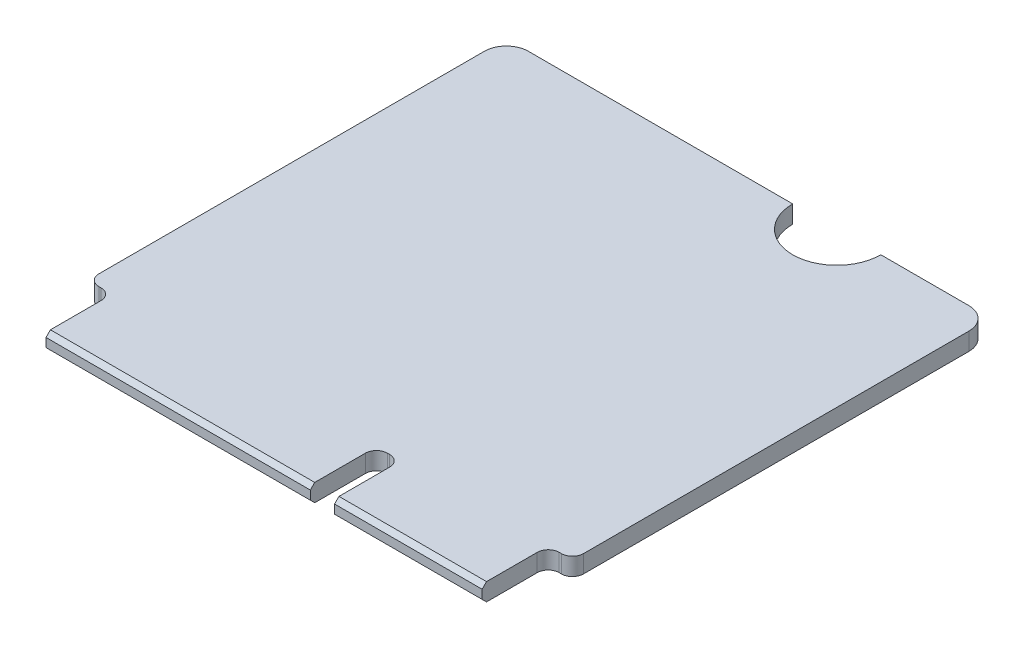
from build123d import *

# Parameters (mm, degrees)
BOSS_EXTRUDE1_DEPTH = 0.8
FILLET1_R           = 1
FILLET2_R           = 0.5
CHAMFER1_SIZE       = 0.2


with BuildPart() as part:
    # Sketch1 → Boss-Extrude1 (new body)
    with BuildSketch(Plane(origin=(0, 0, 0), x_dir=(1, 0, 0), z_dir=(0, 1, 0))):
        with BuildLine():
            Line((14.2, -22), (20.9, -22))
            Line((20.9, -22), (20.9, -19))
            Line((20.9, -19), (22, -19))
            Line((22, -19), (22, 0))
            Line((22, 0), (17, 0))
            ThreePointArc((17, 0), (15, -2), (13, 0))
            Line((13, 0), (0, 0))
            Line((0, 0), (0, -19))
            Line((0, -19), (1.1, -19))
            Line((1.1, -19), (1.1, -22))
            Line((1.1, -22), (13.1, -22))
            Line((13.1, -22), (13.1, -19))
            Line((13.1, -19), (14.2, -19))
            Line((14.2, -19), (14.2, -22))
        make_face()
    extrude(amount=BOSS_EXTRUDE1_DEPTH)

    # Fillet1
    fillet1_edges = [part.edges().sort_by_distance(p)[0] for p in [
        (0, 0.4, 0),
        (22, 0.4, 0),
    ]]
    fillet(fillet1_edges, radius=FILLET1_R)

    # Fillet2
    fillet2_edges = [part.edges().sort_by_distance(p)[0] for p in [
        (22, 0.4, 19),
        (20.9, 0.4, 19),
        (14.2, 0.4, 19),
        (13.1, 0.4, 19),
        (1.1, 0.4, 19),
        (0, 0.4, 19),
    ]]
    fillet(fillet2_edges, radius=FILLET2_R)

    # Chamfer1
    chamfer1_edges = [part.edges().sort_by_distance(p)[0] for p in [
        (17.55, 0, 22),
        (7.1, 0.8, 22),
        (7.1, 0, 22),
        (17.55, 0.8, 22),
    ]]
    chamfer(chamfer1_edges, length=CHAMFER1_SIZE)


solid = part.part
